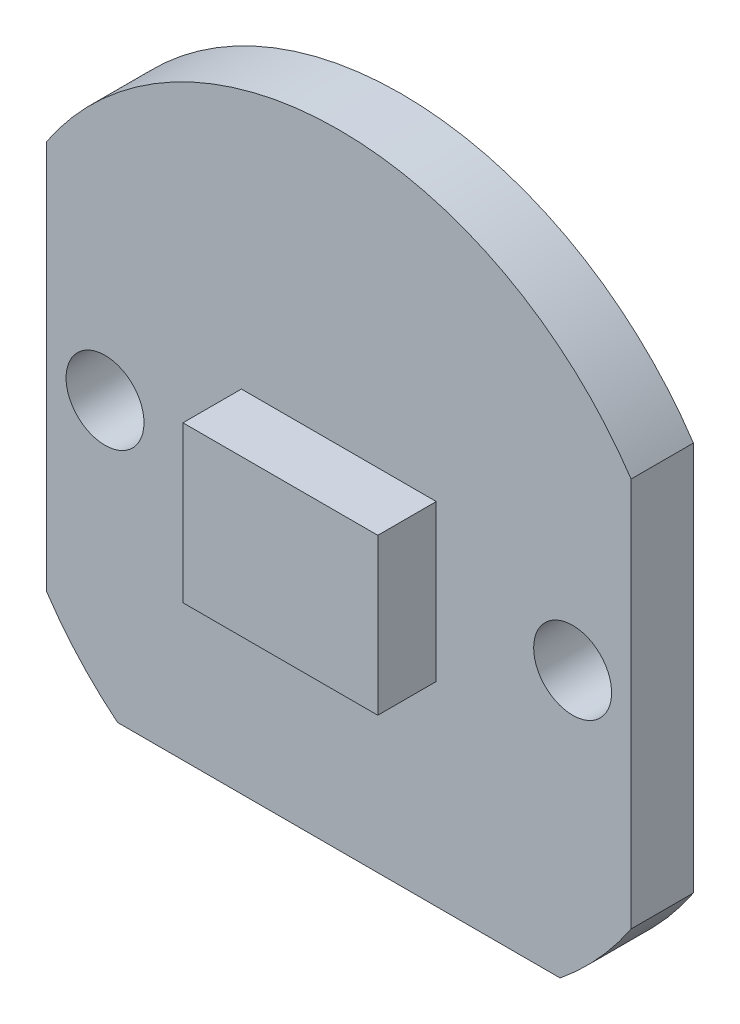
from build123d import *

# Parameters (mm, degrees)
SKETCH1_R           = 1
BOSS_EXTRUDE1_DEPTH = 1.6
SKETCH2_W           = 5
SKETCH2_H           = 4
BOSS_EXTRUDE2_DEPTH = 1.5


with BuildPart() as part:
    # Sketch1 → Boss-Extrude1 (new body)
    with BuildSketch(Plane.XY):
        with BuildLine():
            Line((-5.678908346, -7), (5.678908346, -7))
            ThreePointArc((5.678908346, -7), (6.664901072, -6.068697859), (7.5, -5))
            Line((7.5, -5), (7.5, 5))
            ThreePointArc((7.5, 5), (0, 9.013878189), (-7.5, 5))
            Line((-7.5, 5), (-7.5, -5))
            ThreePointArc((-7.5, -5), (-6.664901072, -6.068697859), (-5.678908346, -7))
        make_face()
        with Locations((-6, 0)):
            Circle(SKETCH1_R, mode=Mode.SUBTRACT)
        with Locations((6, 0)):
            Circle(SKETCH1_R, mode=Mode.SUBTRACT)
    extrude(amount=BOSS_EXTRUDE1_DEPTH)

    # Sketch2 → Boss-Extrude2 (add)
    with BuildSketch(Plane.XY.offset(1.6)):
        Rectangle(SKETCH2_W, SKETCH2_H)
    extrude(amount=BOSS_EXTRUDE2_DEPTH)


solid = part.part
